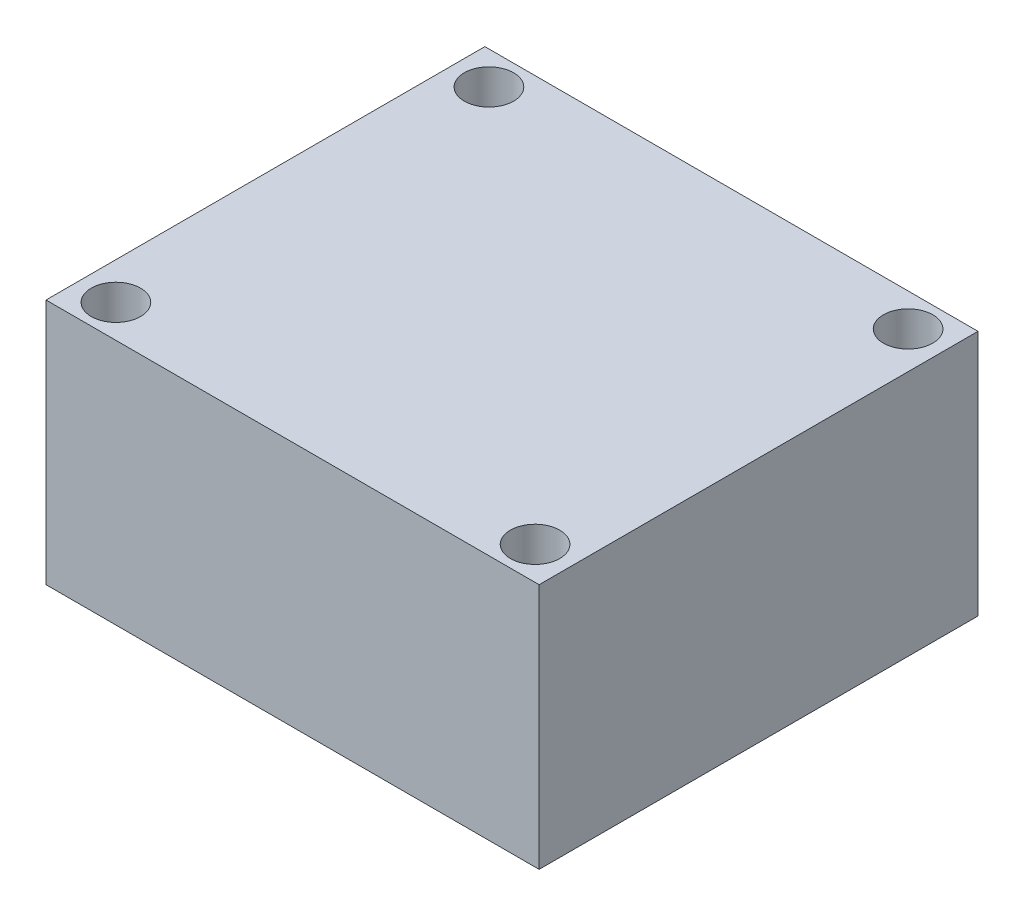
from build123d import *

# Parameters (mm, degrees)
SKETCH1_W           = 20
SKETCH1_H           = 17.8
SKETCH1_R           = 1
BOSS_EXTRUDE1_DEPTH = 10


with BuildPart() as part:
    # Sketch1 → Boss-Extrude1 (new body)
    with BuildSketch(Plane(origin=(0, 0, 0), x_dir=(1, 0, 0), z_dir=(0, 1, 0))):
        with Locations((10, 8.9)):
            Rectangle(SKETCH1_W, SKETCH1_H)
        with Locations((1.5, 16.465)):
            Circle(SKETCH1_R, mode=Mode.SUBTRACT)
        with Locations((1.5, 1.335)):
            Circle(SKETCH1_R, mode=Mode.SUBTRACT)
        with Locations((18.5, 1.335)):
            Circle(SKETCH1_R, mode=Mode.SUBTRACT)
        with Locations((18.5, 16.465)):
            Circle(SKETCH1_R, mode=Mode.SUBTRACT)
    extrude(amount=BOSS_EXTRUDE1_DEPTH)


solid = part.part
